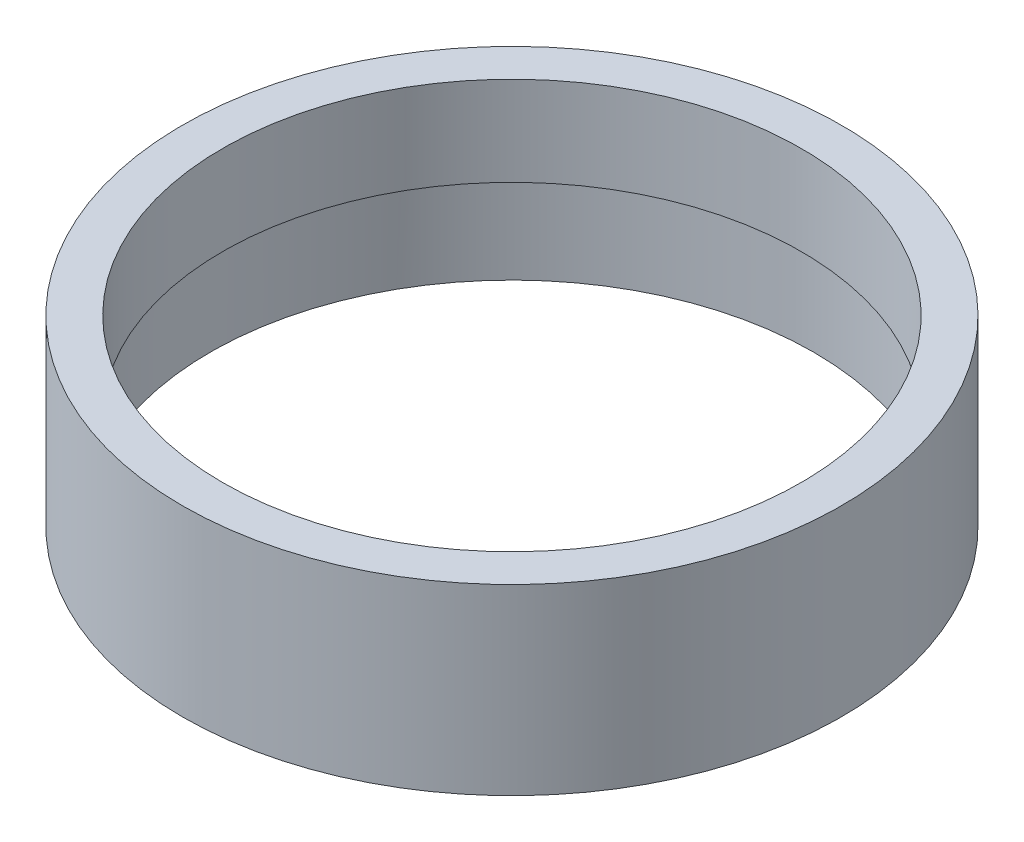
from build123d import *

# Parameters (mm, degrees)
SKETCH1_R           = 77.5
BOSS_EXTRUDE1_DEPTH = 43
SKETCH3_R           = 71
CUT_EXTRUDE1_DEPTH  = 44
SKETCH4_R           = 71
SKETCH4_R_2         = 68.044293834
BOSS_EXTRUDE3_DEPTH = 21


with BuildPart() as part:
    # Sketch1 → Boss-Extrude1 (new body)
    with BuildSketch(Plane(origin=(0, 0, 0), x_dir=(1, 0, 0), z_dir=(0, 1, 0))):
        Circle(SKETCH1_R)
    extrude(amount=BOSS_EXTRUDE1_DEPTH)

    # Sketch3 → Cut-Extrude1 (cut, through all)
    with BuildSketch(Plane.XZ):
        Circle(SKETCH3_R)
    extrude(amount=-CUT_EXTRUDE1_DEPTH, mode=Mode.SUBTRACT)

    # Sketch4 → Boss-Extrude3 (add, through all)
    with BuildSketch(Plane(origin=(0, 22, 0), x_dir=(1, 0, 0), z_dir=(0, 1, 0))):
        Circle(SKETCH4_R)
        Circle(SKETCH4_R_2, mode=Mode.SUBTRACT)
    extrude(amount=BOSS_EXTRUDE3_DEPTH)


solid = part.part
